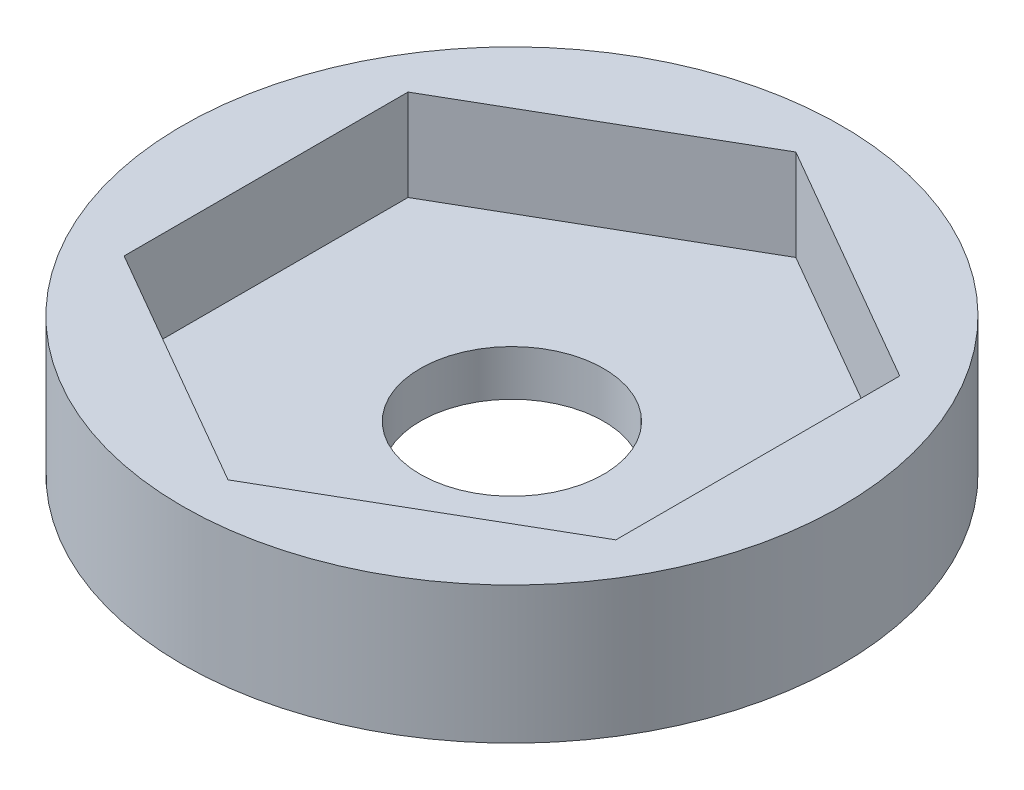
from build123d import *

# Parameters (mm, degrees)
SKETCH1_R           = 11.456840972
BOSS_EXTRUDE1_DEPTH = 3.175
BOSS_EXTRUDE2_START = -1.5875
SKETCH2_R           = 11.456840972
SKETCH2_R_2         = 3.1877
BOSS_EXTRUDE2_DEPTH = 1.5875


with BuildPart() as part:
    # Sketch1 → Boss-Extrude1 (new body)
    with BuildSketch(Plane(origin=(0, 0, 0), x_dir=(1, 0, 0), z_dir=(0, 1, 0))):
        Circle(SKETCH1_R)
        Polygon((8.5471, 4.934670486), (0, 9.869340972), (-8.5471, 4.934670486), (-8.5471, -4.934670486), (0, -9.869340972), (8.5471, -4.934670486), align=None, mode=Mode.SUBTRACT)
    extrude(amount=BOSS_EXTRUDE1_DEPTH)

    # Sketch2 → Boss-Extrude2 (add)
    with BuildSketch(Plane(origin=(0, 0, 0), x_dir=(1, 0, 0), z_dir=(0, 1, 0)).offset(BOSS_EXTRUDE2_START)):
        Circle(SKETCH2_R)
        Circle(SKETCH2_R_2, mode=Mode.SUBTRACT)
    extrude(amount=BOSS_EXTRUDE2_DEPTH)


solid = part.part
